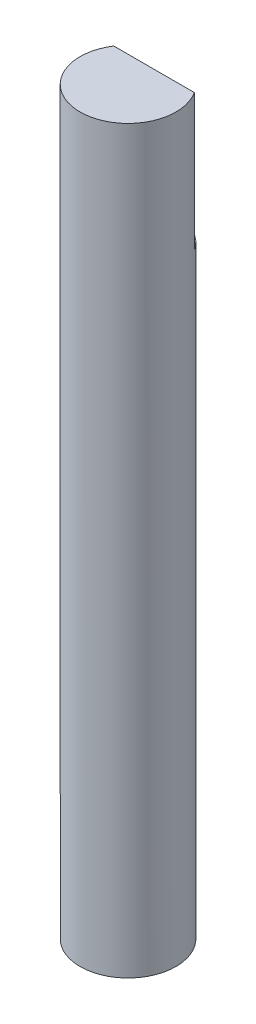
from build123d import *

# Parameters (mm, degrees)
SKETCH_1_R          = 3.5
EXTRUDE_1_DEPTH     = 54
SKETCH_2_W          = 8.789523474
SKETCH_2_H          = 10
CUT_EXTRUDE_1_DEPTH = 10


with BuildPart() as part:
    # 草图1 → 凸台-拉伸1 (new body)
    with BuildSketch(Plane(origin=(0, 0, 0), x_dir=(1, 0, 0), z_dir=(0, 1, 0))):
        Circle(SKETCH_1_R)
    extrude(amount=EXTRUDE_1_DEPTH)

    # 草图2 → 切除-拉伸1 (cut)
    with BuildSketch(Plane(origin=(0, 54, 0), x_dir=(1, 0, 0), z_dir=(0, 1, 0))):
        with Locations((0, 6.9)):
            Rectangle(SKETCH_2_W, SKETCH_2_H)
    extrude(amount=-CUT_EXTRUDE_1_DEPTH, mode=Mode.SUBTRACT)


solid = part.part
